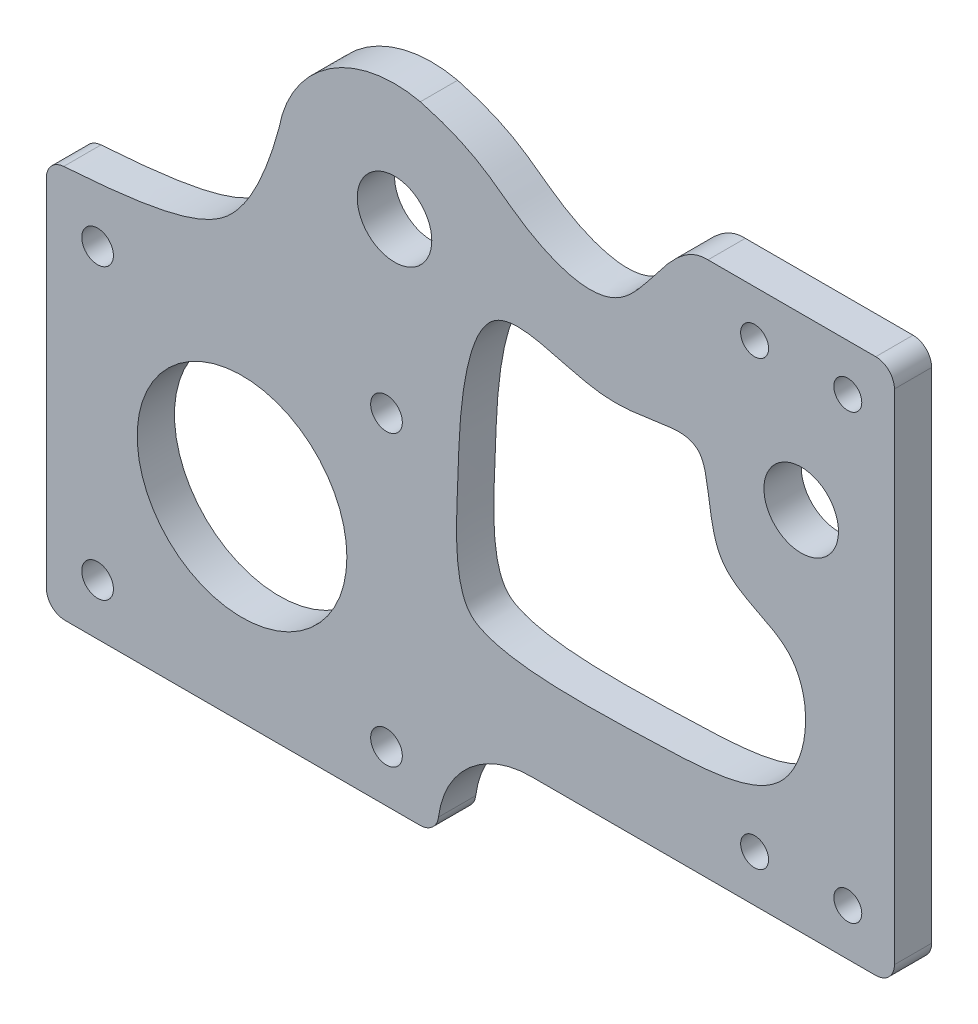
from build123d import *

# Parameters (mm, degrees)
SKETCH_1_R          = 1.7
SKETCH_1_R_2        = 11.25
SKETCH_1_R_3        = 1.5
SKETCH_1_R_4        = 4
EXTRUDE_1_DEPTH     = 4
FILLET_1_R          = 10
FILLET_2_R          = 2
CUT_EXTRUDE_1_DEPTH = 5.0000001


with BuildPart() as part:
    # Эскиз1 → Бобышка-Вытянуть1 (new body)
    with BuildSketch(Plane.XY):
        Polygon((-81, -49.75), (-39, -49.75), (-39, -39.25), (-39, -7.75), (-81, -7.75), align=None)
        with Locations((-75.5, -44.25)):
            Circle(SKETCH_1_R, mode=Mode.SUBTRACT)
        with Locations((-44.5, -44.25)):
            Circle(SKETCH_1_R, mode=Mode.SUBTRACT)
        with Locations((-60, -28.75)):
            Circle(SKETCH_1_R_2, mode=Mode.SUBTRACT)
        with Locations((-75.5, -13.25)):
            Circle(SKETCH_1_R, mode=Mode.SUBTRACT)
        with Locations((-44.5, -13.25)):
            Circle(SKETCH_1_R, mode=Mode.SUBTRACT)
        with BuildLine():
            Line((-39, -7.75), (-39, -39.25))
            Line((-39, -39.25), (10, -39.25))
            Line((10, -39.25), (10, 18.25))
            Line((10, 18.25), (-10, 18.25))
            add(Edge.make_bspline(
                [(-39.319340536, 17.051266286), (-34.354424245, 15.46095429), (-30.776956758, 11.409343943), (-18.078350398, 6.16680142), (-13.969651369, 18.391226568), (-10, 18.25)],
                knots=[0.028412524, 0.028412524, 0.028412524, 0.028412524, 0.320221628, 0.646274516, 1, 1, 1, 1], degree=3))
            ThreePointArc((-39.319340536, 17.051266286), (-33.314916576, 12.437436783), (-31.039498728, 5.215040823))
            ThreePointArc((-31.039498728, 5.215040823), (-44.778968988, -7.333329889), (-56.033404684, 7.484643241))
            add(Edge.make_bspline(
                [(-81, -7.75), (-71.28835503, -7.189860291), (-65.218736855, -6.07286439), (-59.253174463, -1.959633542), (-57.140692046, 3.344616696), (-56.033404684, 7.484643241)],
                knots=[0, 0, 0, 0, 0.43469238, 0.53469238, 1, 1, 1, 1], degree=3))
            Line((-81, -7.75), (-39, -7.75))
        make_face()
        with Locations((-5, -34.25)):
            Circle(SKETCH_1_R_3, mode=Mode.SUBTRACT)
        with Locations((5, -34.25)):
            Circle(SKETCH_1_R_3, mode=Mode.SUBTRACT)
        Circle(SKETCH_1_R_4, mode=Mode.SUBTRACT)
        with Locations((-5, 13.25)):
            Circle(SKETCH_1_R_3, mode=Mode.SUBTRACT)
        with Locations((5, 13.25)):
            Circle(SKETCH_1_R_3, mode=Mode.SUBTRACT)
        with BuildLine():
            ThreePointArc((-40.866697302, 17.506158439), (-50.585656285, 15.727457062), (-56.033404684, 7.484643241))
            ThreePointArc((-56.033404684, 7.484643241), (-44.778968988, -7.333329889), (-31.039498728, 5.215040823))
            ThreePointArc((-31.039498728, 5.215040823), (-33.314916576, 12.437436783), (-39.319340536, 17.051266286))
            add(Edge.make_bspline(
                [(-40.866697302, 17.506158439), (-40.317227744, 17.357889331), (-39.802758638, 17.206109905), (-39.319340536, 17.051266286)],
                knots=[0, 0, 0, 0, 0.028412524, 0.028412524, 0.028412524, 0.028412524], degree=3))
        make_face()
        with Locations((-43.639498728, 5.215040823)):
            Circle(SKETCH_1_R_4, mode=Mode.SUBTRACT)
    extrude(amount=EXTRUDE_1_DEPTH)

    # Скругление1
    fillet_1_edges = [part.edges().sort_by_distance(p)[0] for p in [
        (-39, -39.25, 2),
    ]]
    fillet(fillet_1_edges, radius=FILLET_1_R)

    # Скругление2
    fillet_2_edges = [part.edges().sort_by_distance(p)[0] for p in [
        (10, 18.25, 2),
        (10, -39.25, 2),
        (-81, -7.75, 2),
        (-39, -49.75, 2),
        (-81, -49.75, 2),
    ]]
    fillet(fillet_2_edges, radius=FILLET_2_R)

    # Эскиз3 → Вырез-Вытянуть1 (cut, through all)
    with BuildSketch(Plane.XY.offset(4)):
        with BuildLine():
            add(Edge.make_bspline(
                [(-34.444956995, -28.178923026), (-30.92189204, -29.962809101), (-15.506060824, -29.521805661), (0.426240635, -28.9341004), (1.723955294, -12.375643904), (-10.335137215, -11.117537822), (-9.692150488, -1.159323532), (-12.562688671, 1.384703024), (-16.208166786, 0.048969686), (-24.577211572, -0.106633828), (-34.894447176, 5.710722292), (-36.675122637, -8.780311091), (-36.854166264, -17.716842521), (-37.534471273, -26.248913676), (-34.791569319, -28.003417633), (-34.444956995, -28.178923026)],
                knots=[0, 0, 0, 0, 0.116395905, 0.228688234, 0.343685308, 0.433680773, 0.513870418, 0.533562537, 0.619819805, 0.643369158, 0.758273909, 0.872764205, 0.896936815, 0.988548535, 1, 1, 1, 1], degree=3))
        make_face()
    extrude(amount=-CUT_EXTRUDE_1_DEPTH, mode=Mode.SUBTRACT)


solid = part.part
